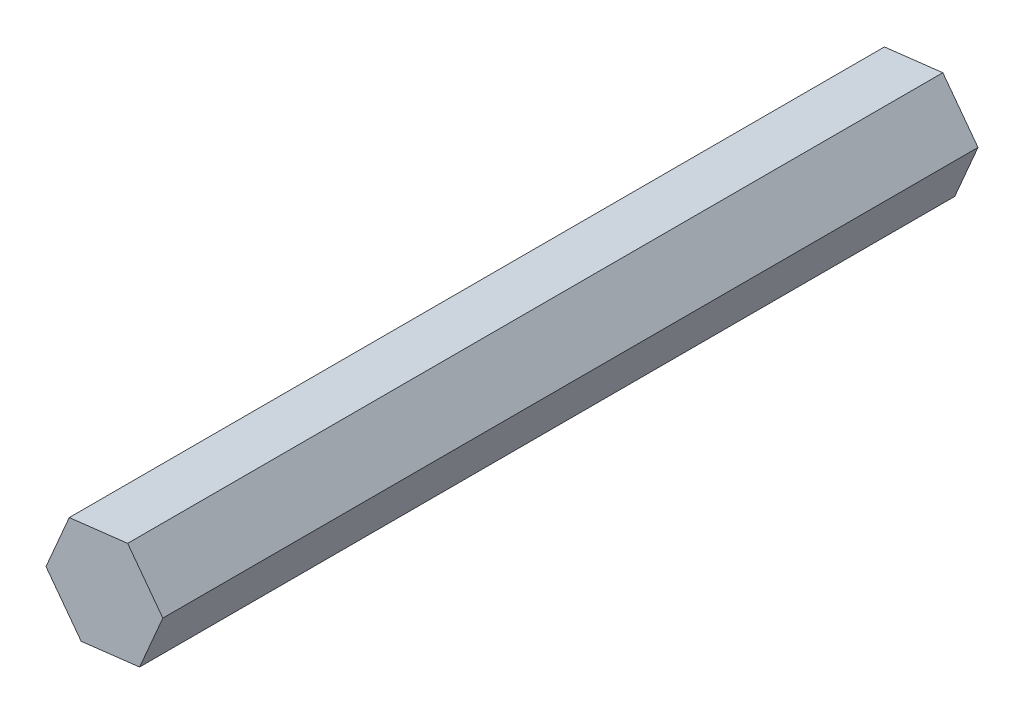
from build123d import *

# Parameters (mm, degrees)
BOSS_EXTRUDE1_DEPTH = 101.6


with BuildPart() as part:
    # Sketch1 → Boss-Extrude1 (new body)
    with BuildSketch(Plane.XY):
        Polygon((-7.281965221, -0.858088492), (-2.897856177, -6.735411116), (4.384109043, -5.877322624), (7.281965221, 0.858088492), (2.897856177, 6.735411116), (-4.384109043, 5.877322624), align=None)
    extrude(amount=BOSS_EXTRUDE1_DEPTH)


solid = part.part
